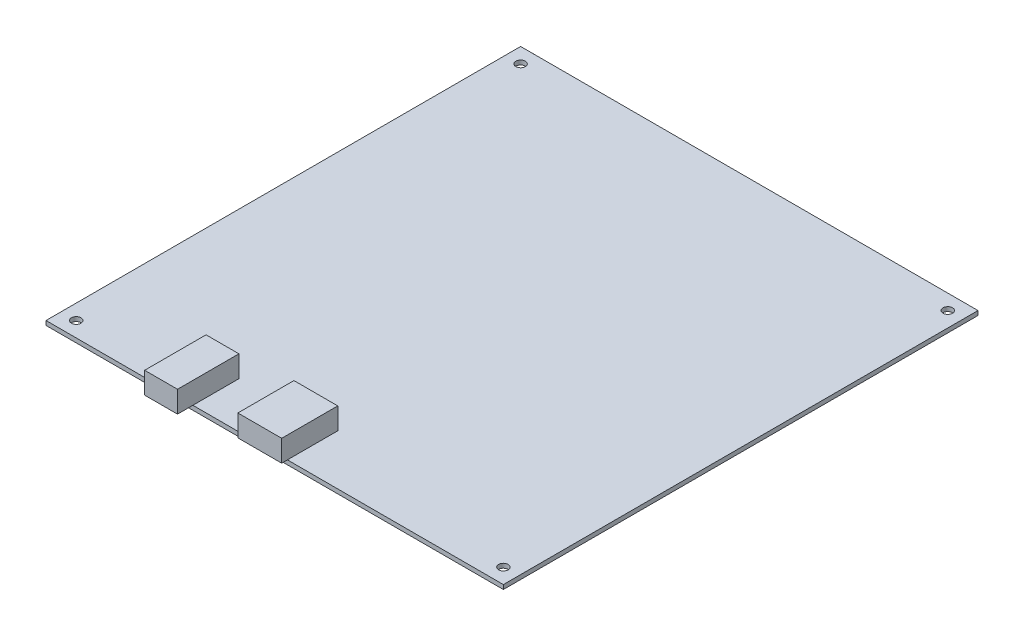
from build123d import *

# Parameters (mm, degrees)
SKETCH1_W           = 106
SKETCH1_H           = 110
SKETCH1_R           = 1.1
BOSS_EXTRUDE1_DEPTH = 1
BOSS_EXTRUDE3_DEPTH = 5
SKETCH3_W           = 10.16
SKETCH3_H           = 13
BOSS_EXTRUDE4_DEPTH = 5


with BuildPart() as part:
    # Sketch1 → Boss-Extrude1 (new body)
    with BuildSketch(Plane(origin=(0, 0, 0), x_dir=(1, 0, 0), z_dir=(0, 1, 0))):
        with Locations((8.955727632, 44.943820005)):
            Rectangle(SKETCH1_W, SKETCH1_H)
        with Locations(Location((-40.544272368, -6.556179995, 0), (0, 0, 270))):
            Circle(SKETCH1_R, mode=Mode.SUBTRACT)
        with Locations(Location((58.455727632, -6.556179995, 0), (0, 0, 270))):
            Circle(SKETCH1_R, mode=Mode.SUBTRACT)
        with Locations(Location((-40.544272368, 96.443820005, 0), (0, 0, 270))):
            Circle(SKETCH1_R, mode=Mode.SUBTRACT)
        with Locations(Location((58.455727632, 96.443820005, 0), (0, 0, 270))):
            Circle(SKETCH1_R, mode=Mode.SUBTRACT)
    extrude(amount=BOSS_EXTRUDE1_DEPTH)

    # 3DSketch1 → Boss-Extrude3 (add)
    with BuildSketch(Plane(origin=(-17.624272368, 1, -0.613820005), x_dir=(0.47206668121683765, 0, 0.8815628443196325), z_dir=(0, -1, 0))):
        Polygon((0, 0), (3.597148111, -6.717508874), (16.141787386, 0), (12.544639275, 6.717508874), align=None)
    extrude(amount=-BOSS_EXTRUDE3_DEPTH)

    # Sketch3 → Boss-Extrude4 (add)
    with BuildSketch(Plane(origin=(0, 1, 0), x_dir=(1, 0, 0), z_dir=(0, 1, 0))):
        with Locations((6.825727632, -4.886179995)):
            Rectangle(SKETCH3_W, SKETCH3_H)
    extrude(amount=BOSS_EXTRUDE4_DEPTH)


solid = part.part
